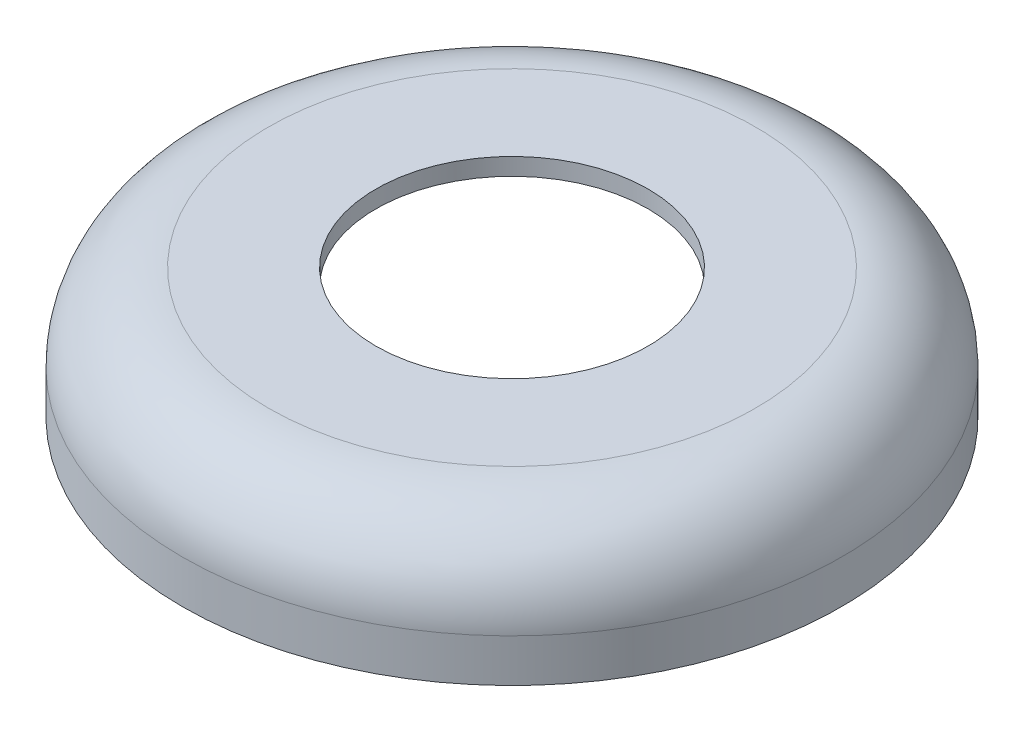
from build123d import *

# Parameters (mm, degrees)
SKETCH1_R           = 11.5
BOSS_EXTRUDE1_DEPTH = 4.5
FILLET2_R           = 3
SHELL1_T            = -0.6
SKETCH2_R           = 4.75
CUT_EXTRUDE1_DEPTH  = 17.874537031


with BuildPart() as part:
    # Sketch1 → Boss-Extrude1 (new body)
    with BuildSketch(Plane(origin=(0, 0, 0), x_dir=(1, 0, 0), z_dir=(0, 1, 0))):
        with Locations(Location((0, 0, 0), (0, 0, 270))):
            Circle(SKETCH1_R)
    extrude(amount=BOSS_EXTRUDE1_DEPTH)

    # Fillet2
    fillet2_edges = [part.edges().sort_by_distance(p)[0] for p in [
        (0, 4.5, -11.5),
    ]]
    fillet(fillet2_edges, radius=FILLET2_R)

    # Shell1
    shell1_openings = [part.faces().sort_by_distance(p)[0] for p in [
        (0, 0, 0),
    ]]
    offset(amount=SHELL1_T, openings=shell1_openings, kind=Kind.INTERSECTION)

    # Sketch2 → Cut-Extrude1 (cut, through all)
    with BuildSketch(Plane(origin=(0, 4.5, 0), x_dir=(1, 0, 0), z_dir=(0, 1, 0))):
        with Locations(Location((0, 0, 0), (0, 0, 270))):
            Circle(SKETCH2_R)
    extrude(amount=-CUT_EXTRUDE1_DEPTH, mode=Mode.SUBTRACT)


solid = part.part
